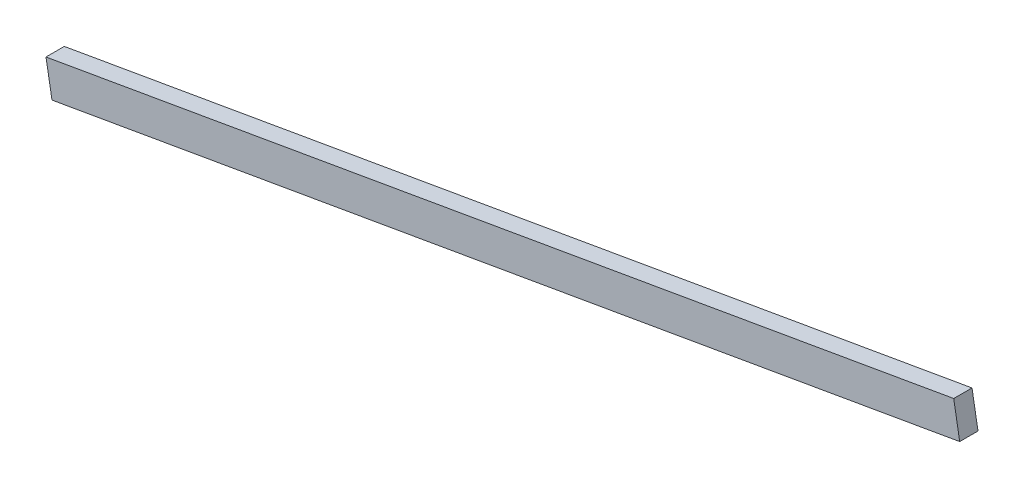
from build123d import *

# Parameters (mm, degrees)
BOSS_EXTRUDE1_DEPTH = 5.334


with BuildPart() as part:
    # Sketch1 → Boss-Extrude1 (new body)
    with BuildSketch(Plane.XY):
        Polygon((-1.743179942, -160.226043692), (262.821283521, -114.150739808), (264.564463463, -124.160081629), (0, -170.235385513), align=None)
    extrude(amount=BOSS_EXTRUDE1_DEPTH)


solid = part.part
